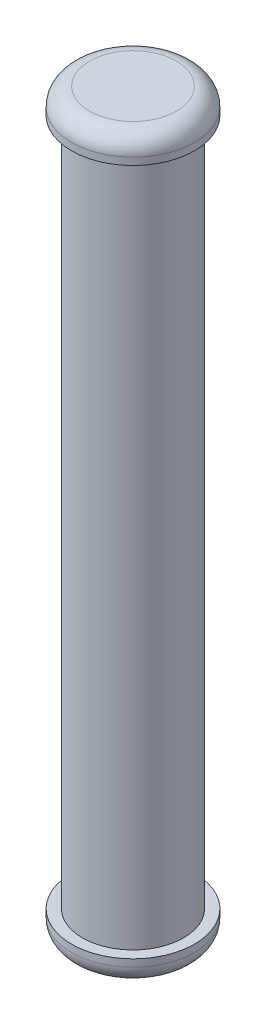
from build123d import *

# Parameters (mm, degrees)
SKETCH1_R           = 1.4
BOSS_EXTRUDE1_DEPTH = 19
SKETCH2_R           = 1.7
BOSS_EXTRUDE2_DEPTH = 0.7
FILLET1_R           = 0.5
SKETCH3_R           = 1.7
BOSS_EXTRUDE3_DEPTH = 0.7
FILLET2_R           = 0.5


with BuildPart() as part:
    # Sketch1 → Boss-Extrude1 (new body)
    with BuildSketch(Plane(origin=(0, 0, 0), x_dir=(1, 0, 0), z_dir=(0, 1, 0))):
        Circle(SKETCH1_R)
    extrude(amount=BOSS_EXTRUDE1_DEPTH)

    # Sketch2 → Boss-Extrude2 (add)
    with BuildSketch(Plane(origin=(0, 19, 0), x_dir=(1, 0, 0), z_dir=(0, 1, 0))):
        Circle(SKETCH2_R)
    extrude(amount=BOSS_EXTRUDE2_DEPTH)

    # Fillet1
    fillet1_edges = [part.edges().sort_by_distance(p)[0] for p in [
        (-1.7, 19.7, 0),
    ]]
    fillet(fillet1_edges, radius=FILLET1_R)

    # Sketch3 → Boss-Extrude3 (add)
    with BuildSketch(Plane.XZ):
        Circle(SKETCH3_R)
    extrude(amount=BOSS_EXTRUDE3_DEPTH)

    # Fillet2
    fillet2_edges = [part.edges().sort_by_distance(p)[0] for p in [
        (-1.7, -0.7, 0),
    ]]
    fillet(fillet2_edges, radius=FILLET2_R)


solid = part.part
